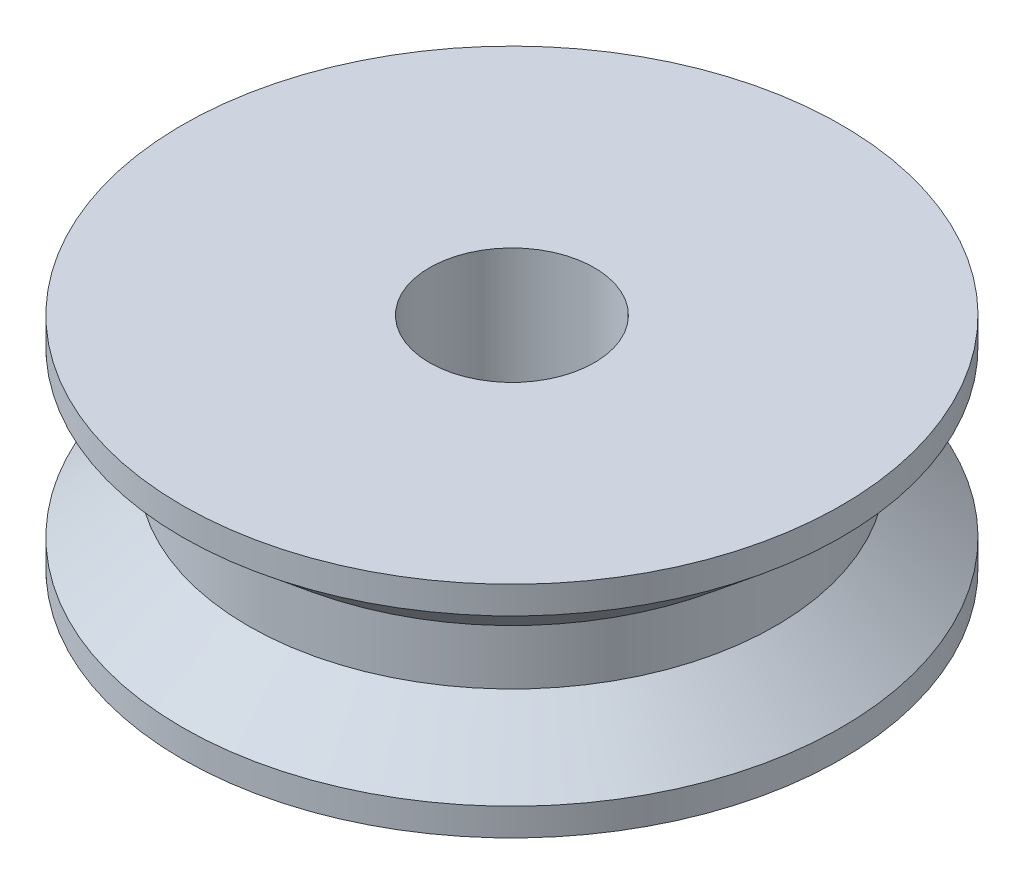
from build123d import *

# Parameters (mm, degrees)
SKETCH1_R           = 6
SKETCH1_R_2         = 1.5
BOSS_EXTRUDE1_DEPTH = 4


with BuildPart() as part:
    # Sketch1 → Boss-Extrude1 (new body)
    with BuildSketch(Plane(origin=(0, 0, 0), x_dir=(1, 0, 0), z_dir=(0, 1, 0))):
        Circle(SKETCH1_R)
        Circle(SKETCH1_R_2, mode=Mode.SUBTRACT)
    extrude(amount=BOSS_EXTRUDE1_DEPTH)

    # Sketch6 → Cut-Revolve1 (revolve, cut)
    with BuildSketch(Plane.XY):
        Polygon((6, 0.5), (6, 3.5), (4.8, 2.5), (4.8, 1.5), align=None)
    revolve(axis=Axis((0, 4, 0), (0, -1, 0)), mode=Mode.SUBTRACT)


solid = part.part
